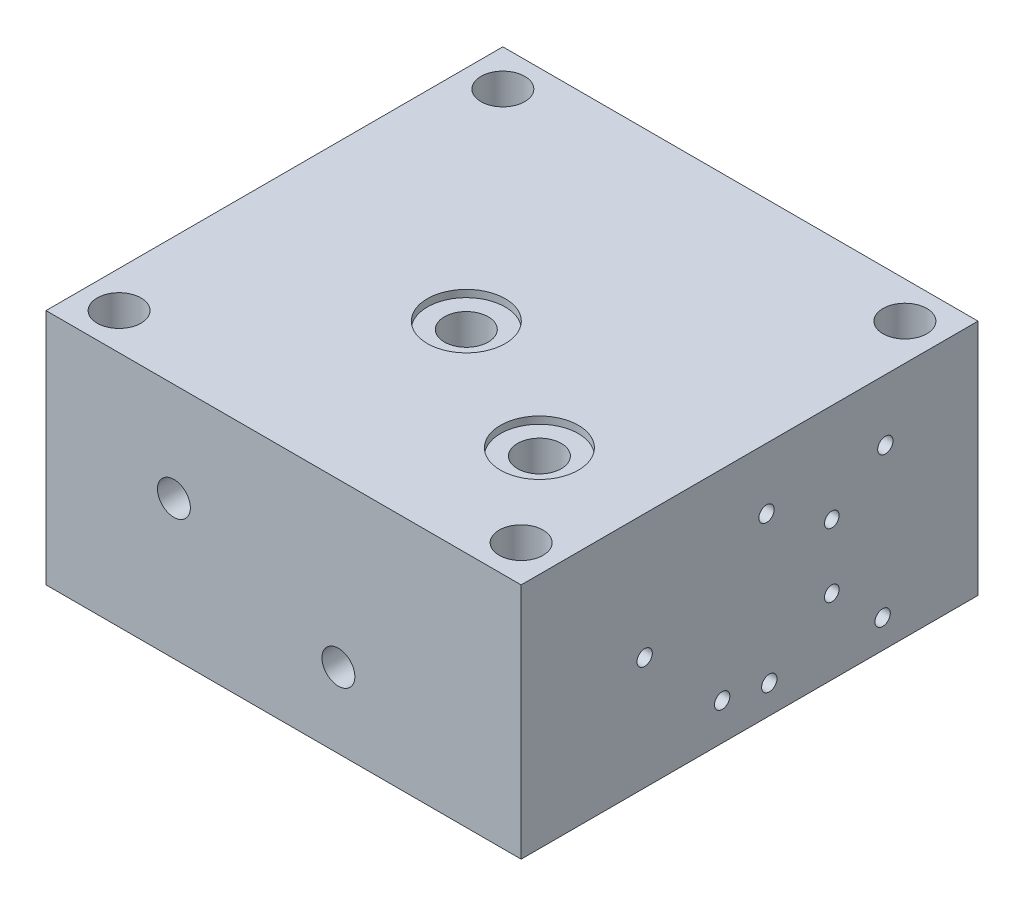
from build123d import *

# Parameters (mm, degrees)
SKETCH_2_W                 = 130
SKETCH_2_H                 = 125
SKETCH_2_R                 = 6
EXTRUDE_1_DEPTH            = 65
HOLE_WIZARD_4_0_4_5_D      = 4
HOLE_WIZARD_M5_3_D         = 4.2
HOLE_WIZARD_M5_3_DEPTH     = 12
HOLE_WIZARD_M5_3_TIP       = 1.2618073
HOLE_WIZARD_4_0_4_9_D      = 4
HOLE_WIZARD_4_0_4_9_DEPTH  = 32.5
HOLE_WIZARD_4_0_4_9_TIP    = 1.201721238
HOLE_WIZARD_6_0_6_1_D      = 6
HOLE_WIZARD_6_0_6_1_DEPTH  = 42
HOLE_WIZARD_6_0_6_1_TIP    = 1.802581857
HOLE_WIZARD_M6_1_D         = 5
HOLE_WIZARD_M6_1_DEPTH     = 13
HOLE_WIZARD_M6_1_TIP       = 1.502151548
HOLE_WIZARD_4_0_4_11_D     = 4
HOLE_WIZARD_4_0_4_11_DEPTH = 85
HOLE_WIZARD_4_0_4_11_TIP   = 1.201721238
M10X1_0_1_D                = 9
M10X1_0_1_DEPTH            = 13
M10X1_0_1_TIP              = 2.703872786
HOLE_WIZARD_1_D            = 12
HOLE_WIZARD_1_DEPTH        = 65
HOLE_WIZARD_1_CBORE_D      = 21.3
HOLE_WIZARD_1_CBORE_DEPTH  = 1.97
HOLE_WIZARD_M5_5_D         = 4.2
HOLE_WIZARD_M5_5_DEPTH     = 10
HOLE_WIZARD_M5_5_TIP       = 1.2618073
HOLE_WIZARD_6_0_6_2_D      = 6
HOLE_WIZARD_6_0_6_2_DEPTH  = 70
HOLE_WIZARD_6_0_6_2_TIP    = 1.802581857
HOLE_WIZARD_6_0_6_3_D      = 6
HOLE_WIZARD_6_0_6_3_DEPTH  = 90
HOLE_WIZARD_6_0_6_3_TIP    = 1.802581857
HOLE_WIZARD_M5_8_D         = 4.2
HOLE_WIZARD_M5_8_DEPTH     = 41.31
HOLE_WIZARD_M5_8_TIP       = 1.2618073
HOLE_WIZARD_6_0_6_4_D      = 6
M10X1_0_2_D                = 9
M10X1_0_2_DEPTH            = 13
M10X1_0_2_TIP              = 2.703872786
HOLE_WIZARD_M5_9_D         = 4.2
HOLE_WIZARD_M5_9_DEPTH     = 70
HOLE_WIZARD_M5_9_TIP       = 1.2618073


with BuildPart() as part:
    # 草图2 → 凸台-拉伸1 (new body)
    with BuildSketch(Plane(origin=(0, 0, 0), x_dir=(1, 0, 0), z_dir=(0, 1, 0))):
        Rectangle(SKETCH_2_W, SKETCH_2_H)
        with Locations((-55, 52.5)):
            Circle(SKETCH_2_R, mode=Mode.SUBTRACT)
        with Locations((55, 52.5)):
            Circle(SKETCH_2_R, mode=Mode.SUBTRACT)
        with Locations((55, -52.5)):
            Circle(SKETCH_2_R, mode=Mode.SUBTRACT)
        with Locations((-55, -52.5)):
            Circle(SKETCH_2_R, mode=Mode.SUBTRACT)
    extrude(amount=EXTRUDE_1_DEPTH)

    # Ø4.0 (4) 直径孔5 (through all)
    with Locations(Plane(origin=(-65, 38, -22.5), x_dir=(0, 0, -1), z_dir=(-1, 0, 0))):
        with Locations((0, 0)):
            Hole(HOLE_WIZARD_4_0_4_5_D / 2)

    # M5 螺纹孔3
    with Locations(Plane(origin=(65, 48.3, -4.65), x_dir=(0, 0, 1), z_dir=(1, 0, 0))):
        with Locations((0, 0), (-32.5, 0), (-31.75, 40.5), (-0.75, 40.5)):
            Hole(HOLE_WIZARD_M5_3_D / 2, depth=HOLE_WIZARD_M5_3_DEPTH)
            with Locations((0, 0, -(HOLE_WIZARD_M5_3_DEPTH + HOLE_WIZARD_M5_3_TIP / 2))):  # 118° drill point
                Cone(0, HOLE_WIZARD_M5_3_D / 2, HOLE_WIZARD_M5_3_TIP, mode=Mode.SUBTRACT)

    # Ø4.0 (4) 直径孔9
    with Locations(Plane(origin=(65, 20.5, -22.49541266), x_dir=(0, 0, 1), z_dir=(1, 0, 0))):
        with Locations((0, 0)):
            Hole(HOLE_WIZARD_4_0_4_9_D / 2, depth=HOLE_WIZARD_4_0_4_9_DEPTH)
            with Locations((0, 0, -(HOLE_WIZARD_4_0_4_9_DEPTH + HOLE_WIZARD_4_0_4_9_TIP / 2))):  # 118° drill point
                Cone(0, HOLE_WIZARD_4_0_4_9_D / 2, HOLE_WIZARD_4_0_4_9_TIP, mode=Mode.SUBTRACT)

    # Ø6.0 (6) 直径孔1
    with Locations(Plane(origin=(32.5, 20.5, -62.5), x_dir=(-1, 0, 0), z_dir=(0, 0, -1))):
        with Locations((0, 0)):
            Hole(HOLE_WIZARD_6_0_6_1_D / 2, depth=HOLE_WIZARD_6_0_6_1_DEPTH)
            with Locations((0, 0, -(HOLE_WIZARD_6_0_6_1_DEPTH + HOLE_WIZARD_6_0_6_1_TIP / 2))):  # 118° drill point
                Cone(0, HOLE_WIZARD_6_0_6_1_D / 2, HOLE_WIZARD_6_0_6_1_TIP, mode=Mode.SUBTRACT)

    # M6 螺纹孔1
    with Locations(Plane(origin=(-65, 52.5, -37), x_dir=(0, 0, -1), z_dir=(-1, 0, 0))):
        with Locations((0, 0), (-29, 0), (0, 29), (-29, 29)):
            Hole(HOLE_WIZARD_M6_1_D / 2, depth=HOLE_WIZARD_M6_1_DEPTH)
            with Locations((0, 0, -(HOLE_WIZARD_M6_1_DEPTH + HOLE_WIZARD_M6_1_TIP / 2))):  # 118° drill point
                Cone(0, HOLE_WIZARD_M6_1_D / 2, HOLE_WIZARD_M6_1_TIP, mode=Mode.SUBTRACT)

    # Ø4.0 (4) 直径孔11
    with Locations(Plane(origin=(-30, 38, 62.5), x_dir=(1, 0, 0), z_dir=(0, 0, 1))):
        with Locations((0, 0)):
            Hole(HOLE_WIZARD_4_0_4_11_D / 2, depth=HOLE_WIZARD_4_0_4_11_DEPTH)
            with Locations((0, 0, -(HOLE_WIZARD_4_0_4_11_DEPTH + HOLE_WIZARD_4_0_4_11_TIP / 2))):  # 118° drill point
                Cone(0, HOLE_WIZARD_4_0_4_11_D / 2, HOLE_WIZARD_4_0_4_11_TIP, mode=Mode.SUBTRACT)

    # M10x1.0 螺纹孔1
    with Locations(Plane(origin=(-30, 38, 62.5), x_dir=(1, 0, 0), z_dir=(0, 0, 1))):
        with Locations((0, 0)):
            Hole(M10X1_0_1_D / 2, depth=M10X1_0_1_DEPTH)
            with Locations((0, 0, -(M10X1_0_1_DEPTH + M10X1_0_1_TIP / 2))):  # 118° drill point
                Cone(0, M10X1_0_1_D / 2, M10X1_0_1_TIP, mode=Mode.SUBTRACT)

    # 孔1
    with Locations(Plane(origin=(-5, 65, 7.5), x_dir=(0, 0, 1), z_dir=(0, 1, 0))):
        with Locations((0, 0), (20, 40)):
            CounterBoreHole(HOLE_WIZARD_1_D / 2, HOLE_WIZARD_1_CBORE_D / 2, HOLE_WIZARD_1_CBORE_DEPTH, depth=HOLE_WIZARD_1_DEPTH)

    # M5 螺纹孔5
    with Locations(Plane(origin=(4.7, 36, -62.5), x_dir=(-1, 0, 0), z_dir=(0, 0, -1))):
        with Locations((0, 0), (-40.5, 0), (-40.5, -31), (0, -31)):
            Hole(HOLE_WIZARD_M5_5_D / 2, depth=HOLE_WIZARD_M5_5_DEPTH)
            with Locations((0, 0, -(HOLE_WIZARD_M5_5_DEPTH + HOLE_WIZARD_M5_5_TIP / 2))):  # 118° drill point
                Cone(0, HOLE_WIZARD_M5_5_D / 2, HOLE_WIZARD_M5_5_TIP, mode=Mode.SUBTRACT)

    # Ø6.0 (6) 直径孔2
    with Locations(Plane(origin=(23.7, 10.1, -62.5), x_dir=(-1, 0, 0), z_dir=(0, 0, -1))):
        with Locations((0, 0)):
            Hole(HOLE_WIZARD_6_0_6_2_D / 2, depth=HOLE_WIZARD_6_0_6_2_DEPTH)
            with Locations((0, 0, -(HOLE_WIZARD_6_0_6_2_DEPTH + HOLE_WIZARD_6_0_6_2_TIP / 2))):  # 118° drill point
                Cone(0, HOLE_WIZARD_6_0_6_2_D / 2, HOLE_WIZARD_6_0_6_2_TIP, mode=Mode.SUBTRACT)

    # Ø6.0 (6) 直径孔3
    with Locations(Plane(origin=(23.7, 30.9, -62.5), x_dir=(-1, 0, 0), z_dir=(0, 0, -1))):
        with Locations((0, 0)):
            Hole(HOLE_WIZARD_6_0_6_3_D / 2, depth=HOLE_WIZARD_6_0_6_3_DEPTH)
            with Locations((0, 0, -(HOLE_WIZARD_6_0_6_3_DEPTH + HOLE_WIZARD_6_0_6_3_TIP / 2))):  # 118° drill point
                Cone(0, HOLE_WIZARD_6_0_6_3_D / 2, HOLE_WIZARD_6_0_6_3_TIP, mode=Mode.SUBTRACT)

    # M5 螺纹孔8
    with Locations(Plane(origin=(65, 30.9, 28.70458734), x_dir=(0, 0, 1), z_dir=(1, 0, 0))):
        with Locations((0, 0)):
            Hole(HOLE_WIZARD_M5_8_D / 2, depth=HOLE_WIZARD_M5_8_DEPTH)
            with Locations((0, 0, -(HOLE_WIZARD_M5_8_DEPTH + HOLE_WIZARD_M5_8_TIP / 2))):  # 118° drill point
                Cone(0, HOLE_WIZARD_M5_8_D / 2, HOLE_WIZARD_M5_8_TIP, mode=Mode.SUBTRACT)

    # Ø6.0 (6) 直径孔4 (through all)
    with Locations(Plane(origin=(15, 20.5, -62.5), x_dir=(-1, 0, 0), z_dir=(0, 0, -1))):
        with Locations((0, 0)):
            Hole(HOLE_WIZARD_6_0_6_4_D / 2)

    # M10x1.0 螺纹孔2
    with Locations(Plane(origin=(15, 20.5, 62.5), x_dir=(1, 0, 0), z_dir=(0, 0, 1))):
        with Locations((0, 0)):
            Hole(M10X1_0_2_D / 2, depth=M10X1_0_2_DEPTH)
            with Locations((0, 0, -(M10X1_0_2_DEPTH + M10X1_0_2_TIP / 2))):  # 118° drill point
                Cone(0, M10X1_0_2_D / 2, M10X1_0_2_TIP, mode=Mode.SUBTRACT)

    # M5 螺纹孔9
    with Locations(Plane(origin=(65, 10.1, 7.5), x_dir=(0, 0, 1), z_dir=(1, 0, 0))):
        with Locations((0, 0)):
            Hole(HOLE_WIZARD_M5_9_D / 2, depth=HOLE_WIZARD_M5_9_DEPTH)
            with Locations((0, 0, -(HOLE_WIZARD_M5_9_DEPTH + HOLE_WIZARD_M5_9_TIP / 2))):  # 118° drill point
                Cone(0, HOLE_WIZARD_M5_9_D / 2, HOLE_WIZARD_M5_9_TIP, mode=Mode.SUBTRACT)


solid = part.part
